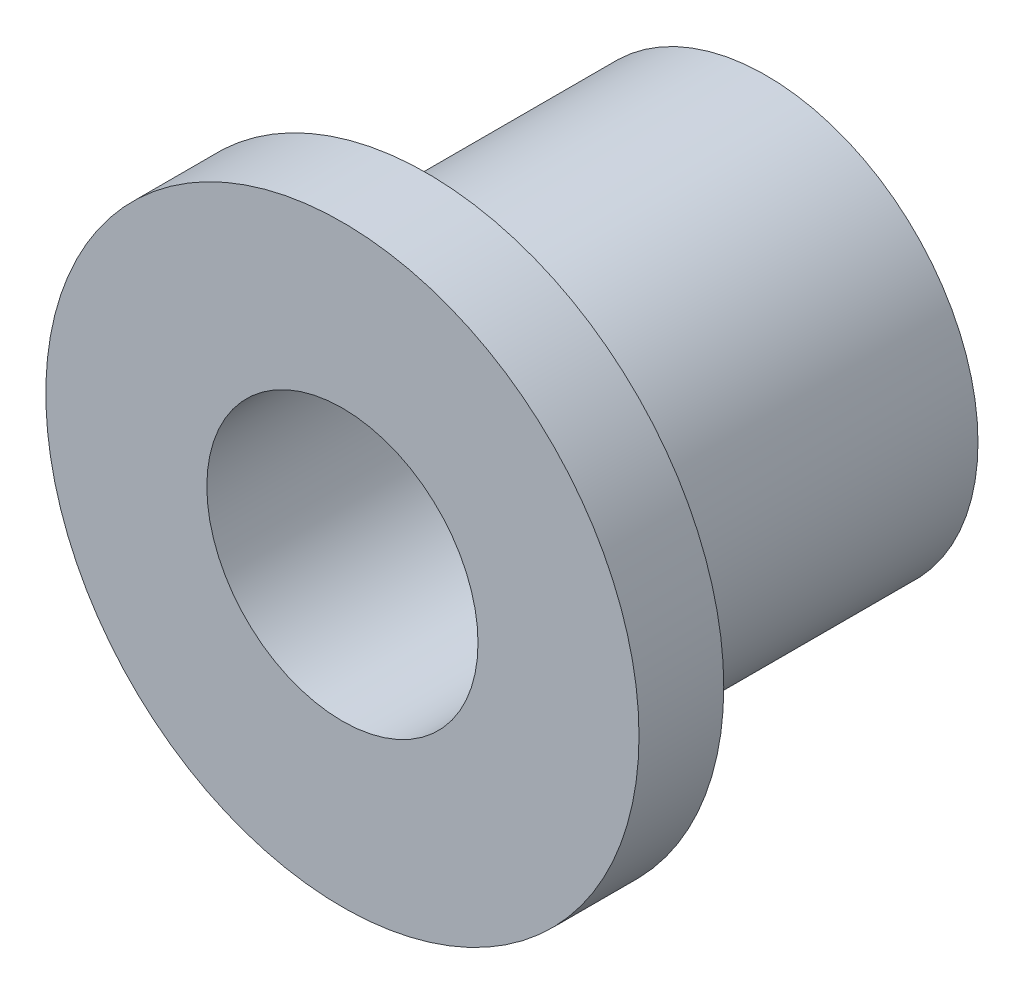
from build123d import *

# Parameters (mm, degrees)
SKETCH_1_R      = 2.5
SKETCH_1_R_2    = 1.6
EXTRUDE_1_DEPTH = 4
SKETCH_2_R      = 3.5
SKETCH_2_R_2    = 1.6
EXTRUDE_2_DEPTH = 1


with BuildPart() as part:
    # 草图1 → 凸台-拉伸1 (new body)
    with BuildSketch(Plane.XY):
        Circle(SKETCH_1_R)
        Circle(SKETCH_1_R_2, mode=Mode.SUBTRACT)
    extrude(amount=EXTRUDE_1_DEPTH)

    # 草图2 → 凸台-拉伸2 (add)
    with BuildSketch(Plane.XY.offset(4)):
        Circle(SKETCH_2_R)
        Circle(SKETCH_2_R_2, mode=Mode.SUBTRACT)
    extrude(amount=EXTRUDE_2_DEPTH)


solid = part.part
